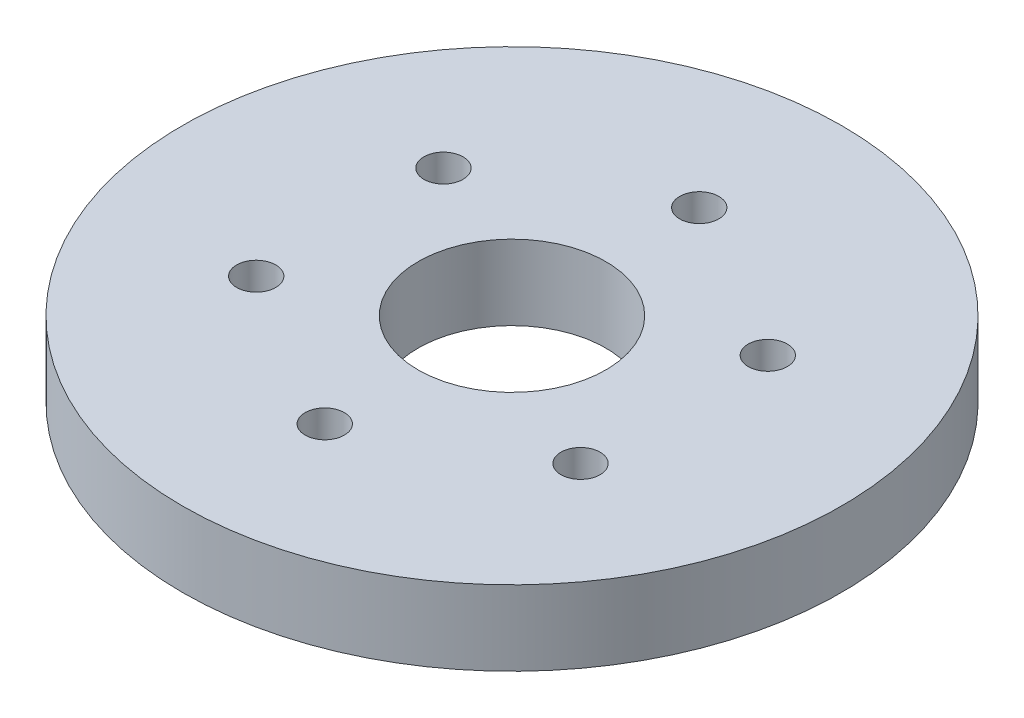
from build123d import *

# Parameters (mm, degrees)
SKETCH1_R           = 41.91
SKETCH1_R_2         = 2.4892
SKETCH1_R_3         = 11.938
BOSS_EXTRUDE1_DEPTH = 9.525


with BuildPart() as part:
    # Sketch1 → Boss-Extrude1 (new body)
    with BuildSketch(Plane.XZ):
        Circle(SKETCH1_R)
        with Locations((-20.622229928, -11.90625)):
            Circle(SKETCH1_R_2, mode=Mode.SUBTRACT)
        with Locations((-20.622229928, 11.90625)):
            Circle(SKETCH1_R_2, mode=Mode.SUBTRACT)
        with Locations((0, 23.8125)):
            Circle(SKETCH1_R_2, mode=Mode.SUBTRACT)
        with Locations((20.622229928, 11.90625)):
            Circle(SKETCH1_R_2, mode=Mode.SUBTRACT)
        with Locations((20.622229928, -11.90625)):
            Circle(SKETCH1_R_2, mode=Mode.SUBTRACT)
        Circle(SKETCH1_R_3, mode=Mode.SUBTRACT)
        with Locations((0, -23.8125)):
            Circle(SKETCH1_R_2, mode=Mode.SUBTRACT)
    extrude(amount=-BOSS_EXTRUDE1_DEPTH)


solid = part.part
